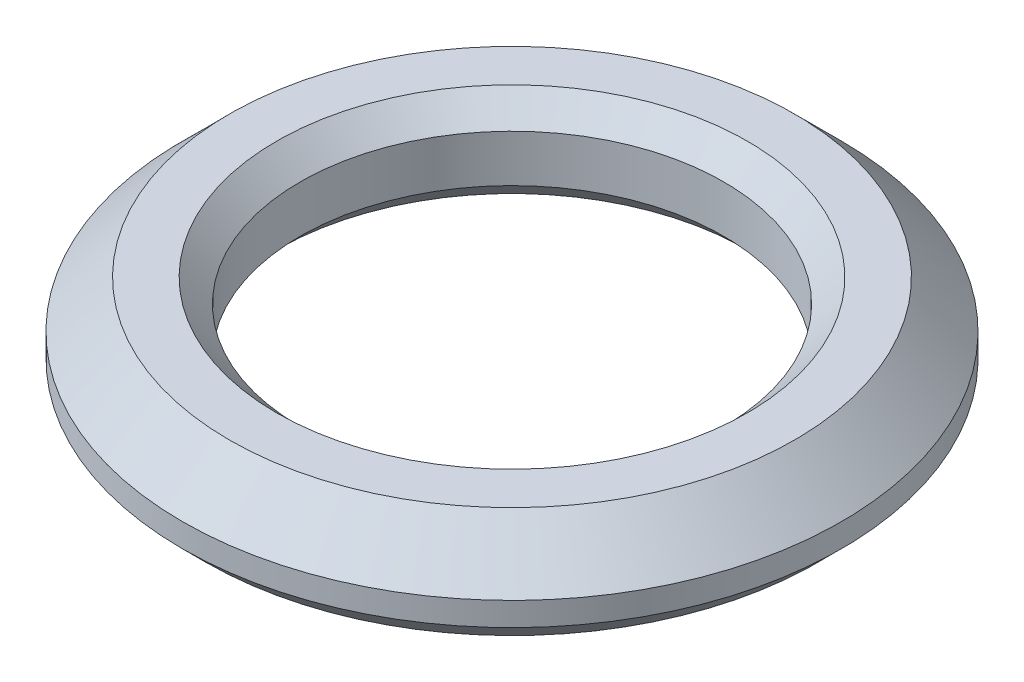
from build123d import *

# Parameters (mm, degrees)
SKETCH1_R           = 7
SKETCH1_R_2         = 4.5
BOSS_EXTRUDE1_DEPTH = 2
CHAMFER1_SIZE       = 1
CHAMFER2_SIZE       = 0.5


with BuildPart() as part:
    # Sketch1 → Boss-Extrude1 (new body)
    with BuildSketch(Plane(origin=(0, 0, 0), x_dir=(1, 0, 0), z_dir=(0, 1, 0))):
        Circle(SKETCH1_R)
        Circle(SKETCH1_R_2, mode=Mode.SUBTRACT)
    extrude(amount=BOSS_EXTRUDE1_DEPTH)

    # Chamfer1
    chamfer1_edges = [part.edges().sort_by_distance(p)[0] for p in [
        (-7, 2, 0),
    ]]
    chamfer(chamfer1_edges, length=CHAMFER1_SIZE)

    # Chamfer2
    chamfer2_edges = [part.edges().sort_by_distance(p)[0] for p in [
        (-7, 0, 0),
        (-4.5, 0, 0),
        (-4.5, 2, 0),
    ]]
    chamfer(chamfer2_edges, length=CHAMFER2_SIZE)


solid = part.part
